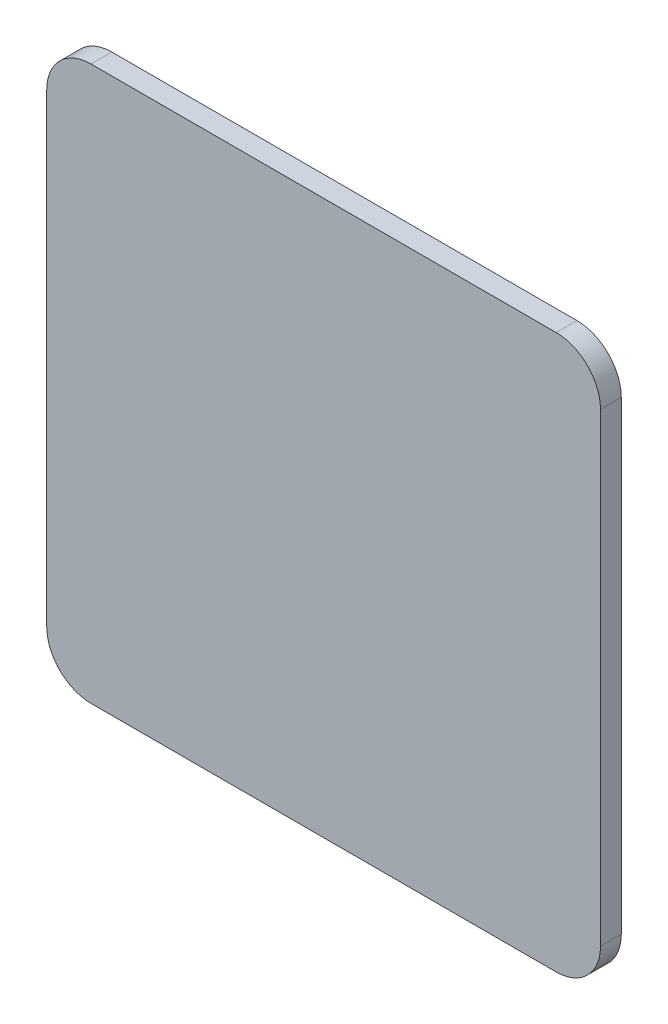
from build123d import *

# Parameters (mm, degrees)
BOSS_EXTRUDE1_DEPTH = 4.7625


with BuildPart() as part:
    # Sketch1 → Boss-Extrude1 (new body)
    with BuildSketch(Plane.XY):
        with BuildLine():
            Line((53.34, 63.5), (-53.34, 63.5))
            ThreePointArc((-53.34, 63.5), (-60.524204897, 60.524204897), (-63.5, 53.34))
            Line((-63.5, 53.34), (-63.5, -53.34))
            ThreePointArc((-63.5, -53.34), (-60.524204897, -60.524204897), (-53.34, -63.5))
            Line((-53.34, -63.5), (53.34, -63.5))
            ThreePointArc((53.34, -63.5), (60.524204897, -60.524204897), (63.5, -53.34))
            Line((63.5, -53.34), (63.5, 53.34))
            ThreePointArc((63.5, 53.34), (60.524204897, 60.524204897), (53.34, 63.5))
        make_face()
        with BuildLine():
            ThreePointArc((58.42, 53.34), (56.932102448, 56.932102448), (53.34, 58.42))
            Line((53.34, 58.42), (-53.34, 58.42))
            ThreePointArc((-53.34, 58.42), (-56.932102448, 56.932102448), (-58.42, 53.34))
            Line((-58.42, 53.34), (-58.42, -53.34))
            ThreePointArc((-58.42, -53.34), (-56.932102448, -56.932102448), (-53.34, -58.42))
            Line((-53.34, -58.42), (53.34, -58.42))
            ThreePointArc((53.34, -58.42), (56.932102448, -56.932102448), (58.42, -53.34))
            Line((58.42, -53.34), (58.42, 53.34))
        make_face(mode=Mode.SUBTRACT)
        with BuildLine():
            Line((58.42, 53.34), (58.42, -53.34))
            ThreePointArc((58.42, -53.34), (56.932102448, -56.932102448), (53.34, -58.42))
            Line((53.34, -58.42), (-53.34, -58.42))
            ThreePointArc((-53.34, -58.42), (-56.932102448, -56.932102448), (-58.42, -53.34))
            Line((-58.42, -53.34), (-58.42, 53.34))
            ThreePointArc((-58.42, 53.34), (-56.932102448, 56.932102448), (-53.34, 58.42))
            Line((-53.34, 58.42), (53.34, 58.42))
            ThreePointArc((53.34, 58.42), (56.932102448, 56.932102448), (58.42, 53.34))
        make_face()
    extrude(amount=BOSS_EXTRUDE1_DEPTH)


solid = part.part
